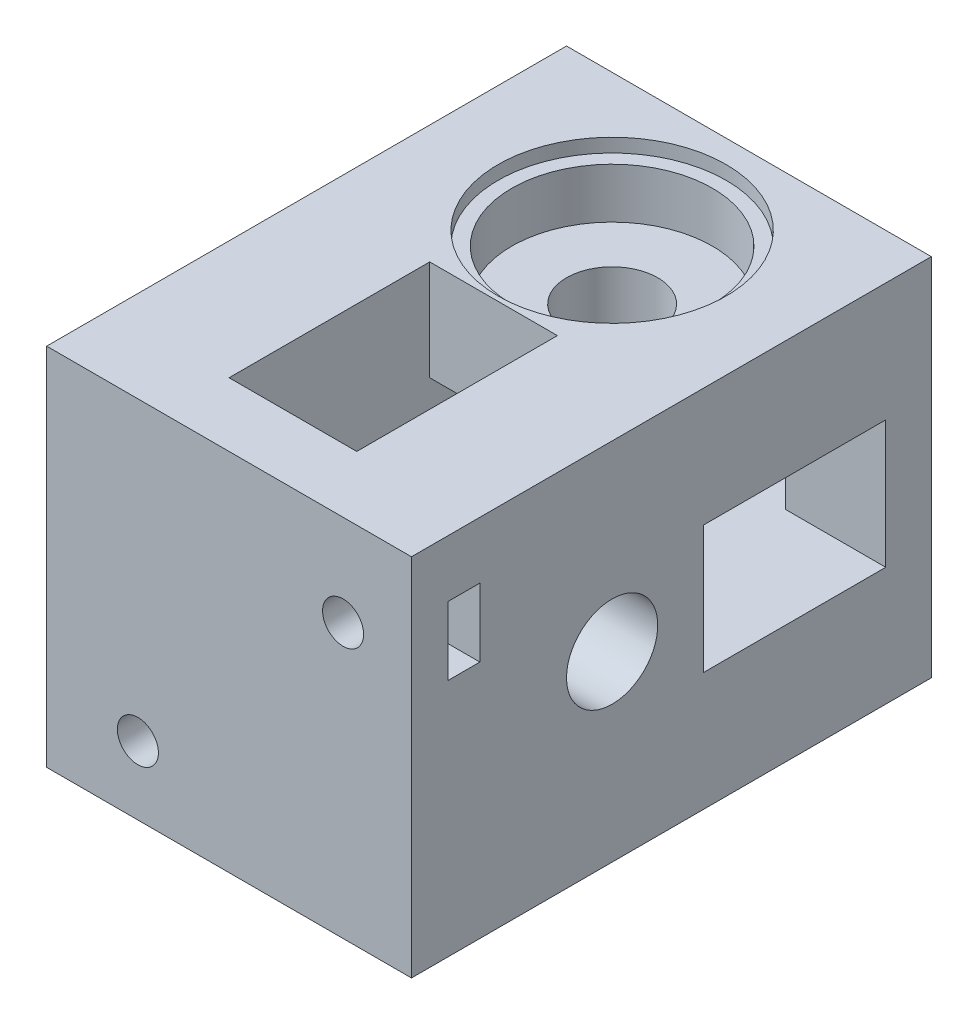
from build123d import *

# Parameters (mm, degrees)
ESQUISSE1_W              = 40
ESQUISSE1_H              = 40
BOSS_EXTRU_1_DEPTH       = 50
ESQUISSE2_R              = 5
ENL_V_MAT_EXTRU_1_DEPTH  = 41
ESQUISSE3_R              = 5
ENL_V_MAT_EXTRU_2_DEPTH  = 41
ESQUISSE4_W              = 22
ESQUISSE4_H              = 14
ENL_V_MAT_EXTRU_3_DEPTH  = 29
ESQUISSE5_W              = 14
ESQUISSE5_H              = 20
ENL_V_MAT_EXTRU_4_DEPTH  = 29
ESQUISSE6_W              = 20
ESQUISSE6_H              = 14
ENL_V_MAT_EXTRU_5_DEPTH  = 24
ESQUISSE7_W              = 14
ESQUISSE7_H              = 22
ENL_V_MAT_EXTRU_6_DEPTH  = 24
ESQUISSE10_R             = 11
ENL_V_MAT_EXTRU_9_DEPTH  = 7
ESQUISSE11_R             = 12.5
ENL_V_MAT_EXTRU_10_DEPTH = 1.5
ESQUISSE14_R             = 11
ENL_V_MAT_EXTRU_11_DEPTH = 7
ESQUISSE15_R             = 12.5
ENL_V_MAT_EXTRU_12_DEPTH = 1.5
ESQUISSE16_W             = 40
ESQUISSE16_H             = 40
BOSS_EXTRU_2_DEPTH       = 7
ESQUISSE17_R             = 2.25
ENL_V_MAT_EXTRU_13_DEPTH = 15
ESQUISSE18_W             = 7
ESQUISSE18_H             = 3
ENL_V_MAT_EXTRU_14_DEPTH = 12
ESQUISSE19_W             = 3.5
ESQUISSE19_H             = 7.5
ENL_V_MAT_EXTRU_15_DEPTH = 12


with BuildPart() as part:
    # Esquisse1 → Boss.-Extru.1 (new body)
    with BuildSketch(Plane.XY):
        with Locations((-20, 20)):
            Rectangle(ESQUISSE1_W, ESQUISSE1_H)
    extrude(amount=BOSS_EXTRU_1_DEPTH)

    # Esquisse2 → Enlèv. mat.-Extru.1 (cut, through all)
    with BuildSketch(Plane(origin=(0, 40, 0), x_dir=(1, 0, 0), z_dir=(0, 1, 0))):
        with Locations(Location((-20, -15, 0), (0, 0, 270))):  # turned: the seam where the file's is
            Circle(ESQUISSE2_R)
    extrude(amount=-ENL_V_MAT_EXTRU_1_DEPTH, mode=Mode.SUBTRACT)

    # Esquisse3 → Enlèv. mat.-Extru.2 (cut, through all)
    with BuildSketch(Plane.ZY.offset(40)):
        with Locations((35, 20)):
            Circle(ESQUISSE3_R)
    extrude(amount=-ENL_V_MAT_EXTRU_2_DEPTH, mode=Mode.SUBTRACT)

    # Esquisse4 → Enlèv. mat.-Extru.3 (cut)
    with BuildSketch(Plane.ZY.offset(40)):
        with Locations((11, 20)):
            Rectangle(ESQUISSE4_W, ESQUISSE4_H)
    extrude(amount=-ENL_V_MAT_EXTRU_3_DEPTH, mode=Mode.SUBTRACT)

    # Esquisse5 → Enlèv. mat.-Extru.4 (cut)
    with BuildSketch(Plane.XZ):
        with Locations((-20, 35)):
            Rectangle(ESQUISSE5_W, ESQUISSE5_H)
    extrude(amount=-ENL_V_MAT_EXTRU_4_DEPTH, mode=Mode.SUBTRACT)

    # Esquisse6 → Enlèv. mat.-Extru.5 (cut)
    with BuildSketch(Plane(origin=(0, 0, 0), x_dir=(0, 0, -1), z_dir=(1, 0, 0))):
        with Locations((-15, 20)):
            Rectangle(ESQUISSE6_W, ESQUISSE6_H)
    extrude(amount=-ENL_V_MAT_EXTRU_5_DEPTH, mode=Mode.SUBTRACT)

    # Esquisse7 → Enlèv. mat.-Extru.6 (cut)
    with BuildSketch(Plane(origin=(0, 40, 0), x_dir=(1, 0, 0), z_dir=(0, 1, 0))):
        with Locations((-20, -39)):
            Rectangle(ESQUISSE7_W, ESQUISSE7_H)
    extrude(amount=-ENL_V_MAT_EXTRU_6_DEPTH, mode=Mode.SUBTRACT)

    # Esquisse10 → Enlèv. mat.-Extru.9 (cut)
    with BuildSketch(Plane(origin=(0, 40, 0), x_dir=(1, 0, 0), z_dir=(0, 1, 0))):
        with Locations(Location((-20, -15, 0), (0, 0, 270))):  # turned: the seam where the file's is
            Circle(ESQUISSE10_R)
    extrude(amount=-ENL_V_MAT_EXTRU_9_DEPTH, mode=Mode.SUBTRACT)

    # Esquisse11 → Enlèv. mat.-Extru.10 (cut)
    with BuildSketch(Plane(origin=(0, 40, 0), x_dir=(1, 0, 0), z_dir=(0, 1, 0))):
        with Locations(Location((-20, -15, 0), (0, 0, 270))):  # turned: the seam where the file's is
            Circle(ESQUISSE11_R)
    extrude(amount=-ENL_V_MAT_EXTRU_10_DEPTH, mode=Mode.SUBTRACT)

    # Esquisse14 → Enlèv. mat.-Extru.11 (cut)
    with BuildSketch(Plane.ZY.offset(40)):
        with Locations((35, 20)):
            Circle(ESQUISSE14_R)
    extrude(amount=-ENL_V_MAT_EXTRU_11_DEPTH, mode=Mode.SUBTRACT)

    # Esquisse15 → Enlèv. mat.-Extru.12 (cut)
    with BuildSketch(Plane.ZY.offset(40)):
        with Locations((35, 20)):
            Circle(ESQUISSE15_R)
    extrude(amount=-ENL_V_MAT_EXTRU_12_DEPTH, mode=Mode.SUBTRACT)

    # Esquisse16 → Boss.-Extru.2 (add)
    with BuildSketch(Plane.XY.offset(50)):
        with Locations((-20, 20)):
            Rectangle(ESQUISSE16_W, ESQUISSE16_H)
    extrude(amount=BOSS_EXTRU_2_DEPTH)

    # Esquisse17 → Enlèv. mat.-Extru.13 (cut)
    with BuildSketch(Plane.XY.offset(57)):
        with Locations((-30, 7.5)):
            Circle(ESQUISSE17_R)
        with Locations((-7.5, 30)):
            Circle(ESQUISSE17_R)
    extrude(amount=-ENL_V_MAT_EXTRU_13_DEPTH, mode=Mode.SUBTRACT)

    # Esquisse18 → Enlèv. mat.-Extru.14 (cut)
    with BuildSketch(Plane.XZ):
        with Locations((-30, 51.5)):
            Rectangle(ESQUISSE18_W, ESQUISSE18_H)
    extrude(amount=-ENL_V_MAT_EXTRU_14_DEPTH, mode=Mode.SUBTRACT)

    # Esquisse19 → Enlèv. mat.-Extru.15 (cut)
    with BuildSketch(Plane(origin=(0, 0, 0), x_dir=(0, 0, -1), z_dir=(1, 0, 0))):
        with Locations((-51.25, 30)):
            Rectangle(ESQUISSE19_W, ESQUISSE19_H)
    extrude(amount=-ENL_V_MAT_EXTRU_15_DEPTH, mode=Mode.SUBTRACT)


solid = part.part
